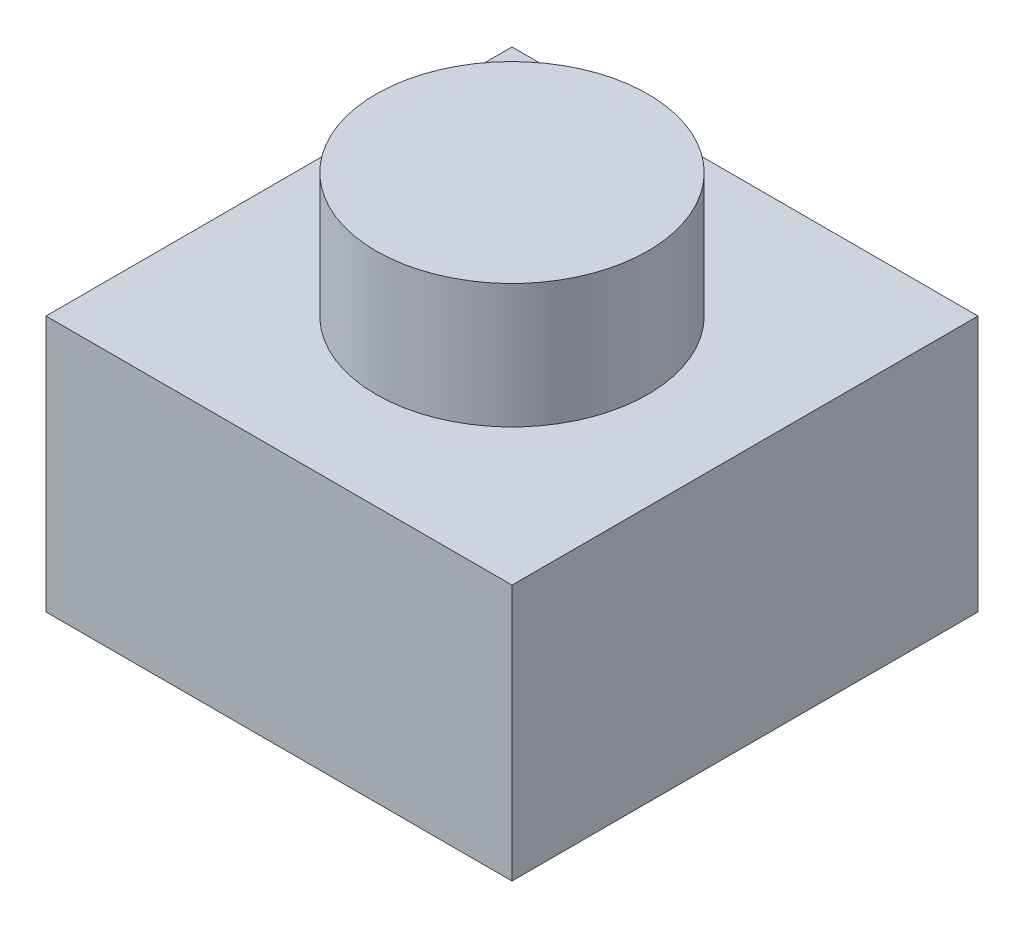
from build123d import *

# Parameters (mm, degrees)
SKETCH1_W           = 6
SKETCH1_H           = 6
BOSS_EXTRUDE1_DEPTH = 3.3
SKETCH2_R           = 1.75
BOSS_EXTRUDE2_DEPTH = 1.6


with BuildPart() as part:
    # Sketch1 → Boss-Extrude1 (new body)
    with BuildSketch(Plane(origin=(0, 0, 0), x_dir=(1, 0, 0), z_dir=(0, 1, 0))):
        Rectangle(SKETCH1_W, SKETCH1_H)
    extrude(amount=BOSS_EXTRUDE1_DEPTH)

    # Sketch2 → Boss-Extrude2 (add)
    with BuildSketch(Plane(origin=(0, 3.3, 0), x_dir=(1, 0, 0), z_dir=(0, 1, 0))):
        Circle(SKETCH2_R)
    extrude(amount=BOSS_EXTRUDE2_DEPTH)


solid = part.part
